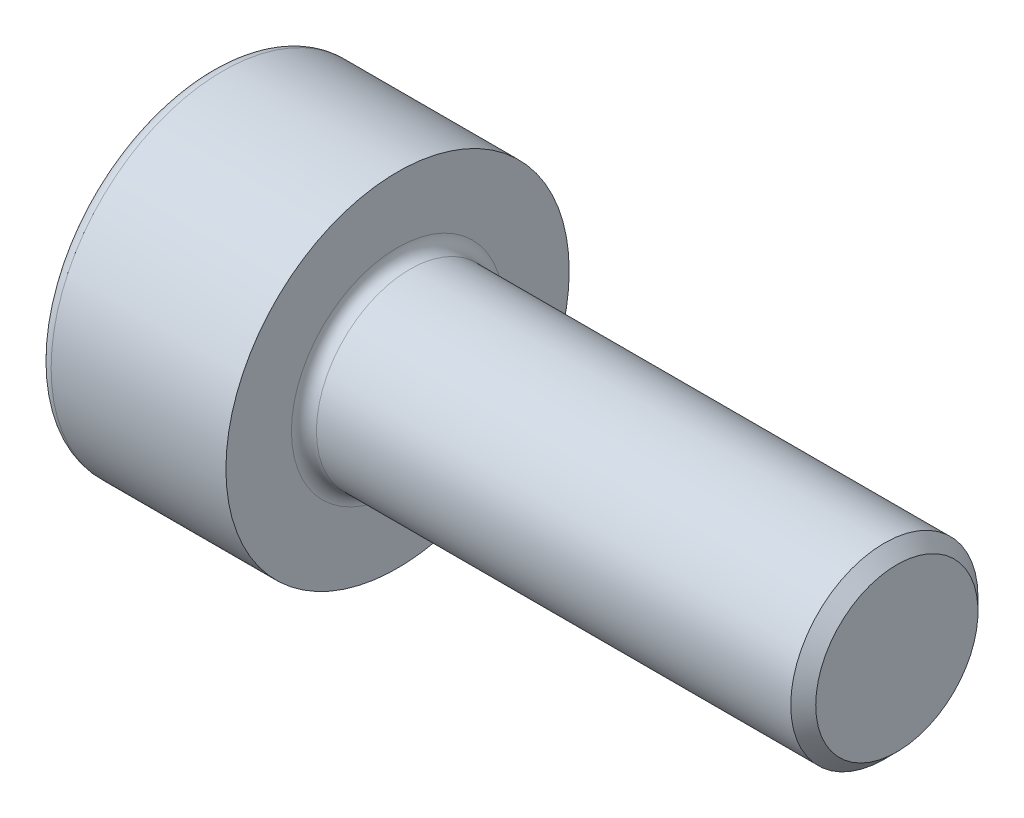
from build123d import *

# Parameters (mm, degrees)
CHANFREIN1_SIZE         = 0.2
CONG_1_R                = 0.2
ENL_V_MAT_EXTRU_1_DEPTH = 1.3


with BuildPart() as part:
    # Esquisse1 → Révolution1 (revolve)
    with BuildSketch(Plane.XY):
        Polygon((0, 0), (0, 2.75), (3, 2.75), (3, 1.5), (11, 1.5), (11, 0), align=None)
    revolve(axis=Axis((0, 0, 0), (1, 0, 0)))

    # Chanfrein1
    chanfrein1_edges = [part.edges().sort_by_distance(p)[0] for p in [
        (11, -1.5, 0),
    ]]
    chamfer(chanfrein1_edges, length=CHANFREIN1_SIZE)

    # Congé1
    cong_1_edges = [part.edges().sort_by_distance(p)[0] for p in [
        (3, -1.5, 0),
        (0, -2.75, 0),
    ]]
    fillet(cong_1_edges, radius=CONG_1_R)

    # Esquisse2 → Enlèv. mat.-Extru.1 (cut)
    with BuildSketch(Plane.ZY):
        Polygon((0.739008345, -1.28), (1.478016689, 0), (0.739008345, 1.28), (-0.739008345, 1.28), (-1.478016689, 0), (-0.739008345, -1.28), align=None)
    extrude(amount=-ENL_V_MAT_EXTRU_1_DEPTH, mode=Mode.SUBTRACT)


solid = part.part
